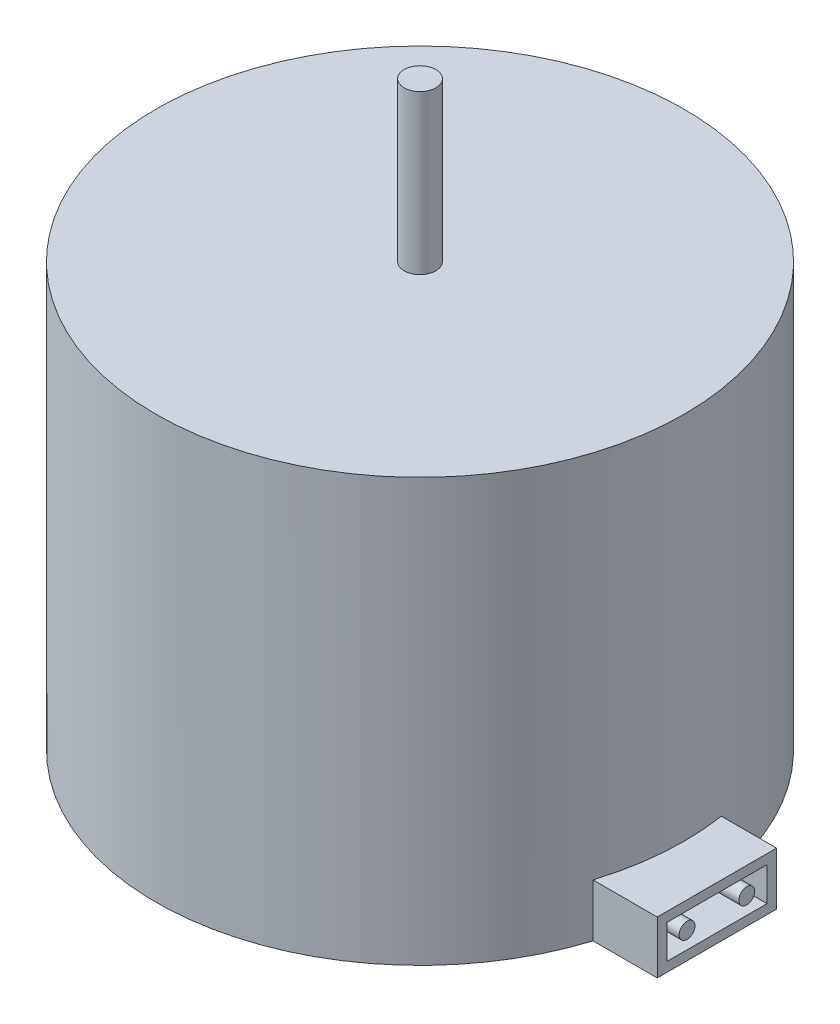
from build123d import *

# Parameters (mm, degrees)
SKETCH1_R           = 25
BOSS_EXTRUDE1_DEPTH = 40
SKETCH2_R           = 1.5
BOSS_EXTRUDE2_DEPTH = 15
SKETCH3_W           = 10
SKETCH3_H           = 11.292423953
BOSS_EXTRUDE3_DEPTH = 5
SKETCH4_W           = 9.492423953
SKETCH4_H           = 3.2
SKETCH4_R           = 0.75
CUT_EXTRUDE1_DEPTH  = 4


with BuildPart() as part:
    # Sketch1 → Boss-Extrude1 (new body)
    with BuildSketch(Plane(origin=(0, 0, 0), x_dir=(1, 0, 0), z_dir=(0, 1, 0))):
        Circle(SKETCH1_R)
    extrude(amount=BOSS_EXTRUDE1_DEPTH)

    # Sketch2 → Boss-Extrude2 (add)
    with BuildSketch(Plane(origin=(0, 40, 0), x_dir=(1, 0, 0), z_dir=(0, 1, 0))):
        Circle(SKETCH2_R)
    extrude(amount=BOSS_EXTRUDE2_DEPTH)

    # Sketch3 → Boss-Extrude3 (add)
    with BuildSketch(Plane.XZ):
        with Locations((24.932644211, 1.833917291)):
            Rectangle(SKETCH3_W, SKETCH3_H)
    extrude(amount=-BOSS_EXTRUDE3_DEPTH)

    # Sketch4 → Cut-Extrude1 (cut)
    with BuildSketch(Plane(origin=(29.932644211, 0, 0), x_dir=(0, 0, -1), z_dir=(1, 0, 0))):
        with Locations((-1.833917291, 2.5)):
            Rectangle(SKETCH4_W, SKETCH4_H)
        with Locations((-4.657023279, 2.5)):
            Circle(SKETCH4_R, mode=Mode.SUBTRACT)
        with Locations((0.989188698, 2.5)):
            Circle(SKETCH4_R, mode=Mode.SUBTRACT)
    extrude(amount=-CUT_EXTRUDE1_DEPTH, mode=Mode.SUBTRACT)


solid = part.part
